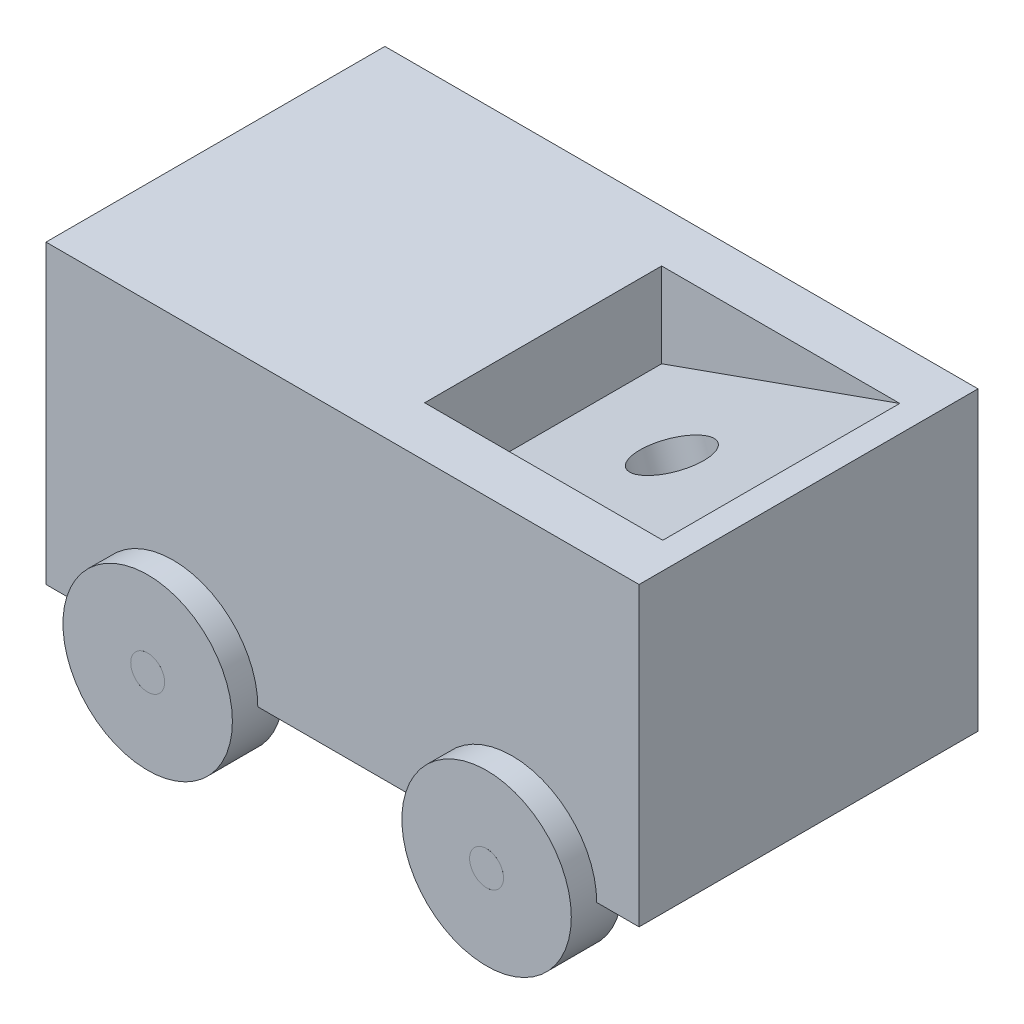
from build123d import *

# Parameters (mm, degrees)
SKETCH2_W                 = 70
SKETCH2_H                 = 35
BOSS_EXTRUDE2_DEPTH       = 40
SKETCH3_W                 = 28.105894453
SKETCH3_H                 = 27.971945797
CUT_EXTRUDE1_DEPTH        = 10
SKETCH4_R                 = 10
CUT_EXTRUDE2_DEPTH        = 3
SKETCH5_R                 = 10
CUT_EXTRUDE3_DEPTH        = 3
SKETCH6_R                 = 10
BOSS_EXTRUDE3_DEPTH       = 3
BOSS_EXTRUDE3_DEPTH_BACK  = 3
SKETCH7_R                 = 10
BOSS_EXTRUDE5_DEPTH       = 6
SKETCH8_R                 = 2
CUT_EXTRUDE5_DEPTH        = 46
SKETCH9_R                 = 2
BOSS_EXTRUDE8_DEPTH       = 0.0001
BOSS_EXTRUDE8_DEPTH_BACK  = 46.0001
SKETCH10_R                = 10
BOSS_EXTRUDE9_DEPTH       = 3
BOSS_EXTRUDE9_DEPTH_BACK  = 3
SKETCH11_R                = 10
BOSS_EXTRUDE10_DEPTH      = 3
BOSS_EXTRUDE10_DEPTH_BACK = 3
SKETCH12_R                = 2
CUT_EXTRUDE6_DEPTH        = 46
SKETCH13_R                = 2
BOSS_EXTRUDE11_DEPTH      = 0.001
BOSS_EXTRUDE11_DEPTH_BACK = 46.001
BOSS_EXTRUDE12_DEPTH      = 28
SKETCH18_R                = 4
CUT_EXTRUDE11_DEPTH       = 10
SKETCH19_R                = 5.5
BOSS_EXTRUDE13_DEPTH      = 0.001


with BuildPart() as part:
    # Sketch2 → Boss-Extrude2 (new body)
    with BuildSketch(Plane.XY):
        with Locations((-35, -17.5)):
            Rectangle(SKETCH2_W, SKETCH2_H)
    extrude(amount=BOSS_EXTRUDE2_DEPTH)

    # Sketch3 → Cut-Extrude1 (cut)
    with BuildSketch(Plane(origin=(0, 0, 0), x_dir=(1, 0, 0), z_dir=(0, 1, 0))):
        with Locations((-17.175677586, -20.094439992)):
            Rectangle(SKETCH3_W, SKETCH3_H)
    extrude(amount=-CUT_EXTRUDE1_DEPTH, mode=Mode.SUBTRACT)

    # Sketch4 → Cut-Extrude2 (cut)
    with BuildSketch(Plane.XY.offset(40)):
        with Locations((-15, -35)):
            Circle(SKETCH4_R)
        with Locations((-55, -35)):
            Circle(SKETCH4_R)
    extrude(amount=-CUT_EXTRUDE2_DEPTH, mode=Mode.SUBTRACT)

    # Sketch5 → Cut-Extrude3 (cut)
    with BuildSketch(Plane(origin=(0, 0, 0), x_dir=(-1, 0, 0), z_dir=(0, 0, -1))):
        with Locations((15, -35)):
            Circle(SKETCH5_R)
        with Locations((55, -35)):
            Circle(SKETCH5_R)
    extrude(amount=-CUT_EXTRUDE3_DEPTH, mode=Mode.SUBTRACT)

    # Sketch6 → Boss-Extrude3 (add, two sides)
    with BuildSketch(Plane.XY.offset(40)) as boss_extrude3_sk:
        with Locations((-55, -35)):
            Circle(SKETCH6_R)
    extrude(amount=BOSS_EXTRUDE3_DEPTH)
    extrude(boss_extrude3_sk.sketch, amount=-BOSS_EXTRUDE3_DEPTH_BACK)

    # Sketch7 → Boss-Extrude5 (add)
    with BuildSketch(Plane(origin=(0, 0, 3), x_dir=(-1, 0, 0), z_dir=(0, 0, -1))):
        with Locations((55, -35)):
            Circle(SKETCH7_R)
    extrude(amount=BOSS_EXTRUDE5_DEPTH)

    # Sketch8 → Cut-Extrude5 (cut)
    with BuildSketch(Plane(origin=(0, 0, -3), x_dir=(-1, 0, 0), z_dir=(0, 0, -1))):
        with Locations((55, -35)):
            Circle(SKETCH8_R)
    extrude(amount=-CUT_EXTRUDE5_DEPTH, mode=Mode.SUBTRACT)

    # Sketch9 → Boss-Extrude8 (add, two sides)
    with BuildSketch(Plane(origin=(0, 0, -3), x_dir=(-1, 0, 0), z_dir=(0, 0, -1))) as boss_extrude8_sk:
        with Locations((55, -35)):
            Circle(SKETCH9_R)
    extrude(amount=BOSS_EXTRUDE8_DEPTH)
    extrude(boss_extrude8_sk.sketch, amount=-BOSS_EXTRUDE8_DEPTH_BACK)

    # Sketch10 → Boss-Extrude9 (add, two sides)
    with BuildSketch(Plane.XY.offset(40)) as boss_extrude9_sk:
        with Locations((-15, -35)):
            Circle(SKETCH10_R)
    extrude(amount=BOSS_EXTRUDE9_DEPTH)
    extrude(boss_extrude9_sk.sketch, amount=-BOSS_EXTRUDE9_DEPTH_BACK)

    # Sketch11 → Boss-Extrude10 (add, two sides)
    with BuildSketch(Plane(origin=(0, 0, 0), x_dir=(-1, 0, 0), z_dir=(0, 0, -1))) as boss_extrude10_sk:
        with Locations((15, -35)):
            Circle(SKETCH11_R)
    extrude(amount=BOSS_EXTRUDE10_DEPTH)
    extrude(boss_extrude10_sk.sketch, amount=-BOSS_EXTRUDE10_DEPTH_BACK)

    # Sketch12 → Cut-Extrude6 (cut)
    with BuildSketch(Plane(origin=(0, 0, -3), x_dir=(-1, 0, 0), z_dir=(0, 0, -1))):
        with Locations((15, -35)):
            Circle(SKETCH12_R)
    extrude(amount=-CUT_EXTRUDE6_DEPTH, mode=Mode.SUBTRACT)

    # Sketch13 → Boss-Extrude11 (add, two sides)
    with BuildSketch(Plane(origin=(0, 0, -3), x_dir=(-1, 0, 0), z_dir=(0, 0, -1))) as boss_extrude11_sk:
        with Locations((15, -35)):
            Circle(SKETCH13_R)
    extrude(amount=BOSS_EXTRUDE11_DEPTH)
    extrude(boss_extrude11_sk.sketch, amount=-BOSS_EXTRUDE11_DEPTH_BACK)

    # Sketch14 → Boss-Extrude12 (add)
    with BuildSketch(Plane(origin=(0, 0, 34.080412891), x_dir=(-1, 0, 0), z_dir=(0, 0, -1))):
        Polygon((3.122730359, 0), (31.228624812, -10), (3.122730359, -10), align=None)
    extrude(amount=BOSS_EXTRUDE12_DEPTH)

    # Sketch18 → Cut-Extrude11 (cut)
    with BuildSketch(Plane(origin=(-0.350891722, 0.986212569, 0), x_dir=(0.942142791, 0.335211816, 0), z_dir=(-0.335211816, 0.942142791, 0))):
        with Locations((-16.374329601, -20.352535637)):
            Circle(SKETCH18_R)
    extrude(amount=-CUT_EXTRUDE11_DEPTH, mode=Mode.SUBTRACT)

    # Sketch19 → Boss-Extrude13 (add)
    with BuildSketch(Plane.ZY.offset(70)):
        with Locations((20, -5.5)):
            Circle(SKETCH19_R)
    extrude(amount=BOSS_EXTRUDE13_DEPTH)


solid = part.part
